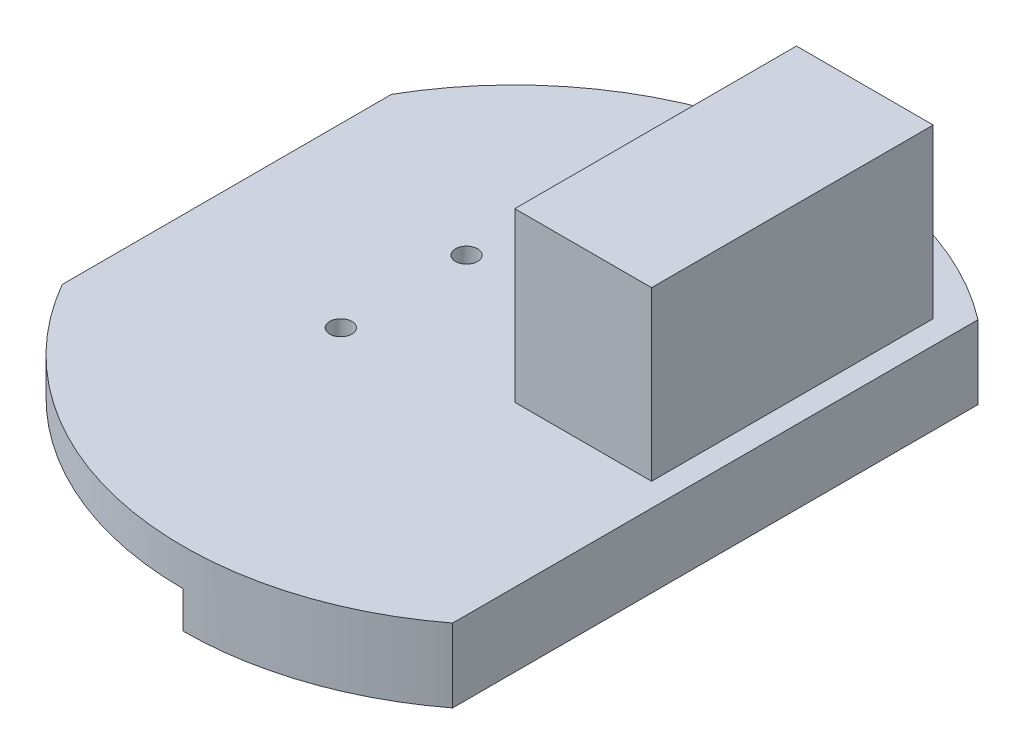
from build123d import *

# Parameters (mm, degrees)
SKETCH_1_R          = 1.5
EXTRUDE_1_DEPTH     = 5
SKETCH_3_W          = 18.6
SKETCH_3_H          = 38.3
SKETCH_3_W_2        = 12.6
SKETCH_3_H_2        = 32.3
EXTRUDE_3_DEPTH     = 19.8
SKETCH_4_W          = 18.6
SKETCH_4_H          = 38.3
EXTRUDE_4_DEPTH     = 3
SKETCH_7_W          = 12.6
SKETCH_7_H          = 32.3
CUT_EXTRUDE_1_DEPTH = 5
SKETCH_8_W          = 35.927581395
SKETCH_8_H          = 53.234071865
CUT_EXTRUDE_2_DEPTH = 14.8
SKETCH_9_W          = 12.6
SKETCH_9_H          = 4.7
EXTRUDE_5_DEPTH     = 15.2
SKETCH_10_R         = 1.1
CUT_EXTRUDE_3_DEPTH = 10
EXTRUDE_6_DEPTH     = 5
SKETCH_13_R         = 1
CUT_EXTRUDE_4_DEPTH = 5


with BuildPart() as part:
    # 草图1 → 凸台-拉伸1 (new body)
    with BuildSketch(Plane(origin=(0, 0, 0), x_dir=(1, 0, 0), z_dir=(0, 1, 0))):
        with BuildLine():
            Line((-39.038561358, -22.382822144), (-39.038561358, 22.382822144))
            ThreePointArc((-39.038561358, 22.382822144), (-8.857541047, 44.119655105), (27.374530931, 35.716033603))
            Line((27.374530931, 35.716033603), (27.374530931, -35.716033603))
            ThreePointArc((27.374530931, -35.716033603), (-8.857541047, -44.119655105), (-39.038561358, -22.382822144))
        make_face()
        with Locations((-15, 8.55)):
            Circle(SKETCH_1_R, mode=Mode.SUBTRACT)
        with Locations((-15, -8.55)):
            Circle(SKETCH_1_R, mode=Mode.SUBTRACT)
    extrude(amount=EXTRUDE_1_DEPTH)

    # 草图3 → 凸台-拉伸3 (add, symmetric)
    with BuildSketch(Plane(origin=(0, 5, 0), x_dir=(1, 0, 0), z_dir=(0, 1, 0))):
        with Locations((14.904530931, 13.65)):
            Rectangle(SKETCH_3_W, SKETCH_3_H)
        with Locations((14.904530931, 13.65)):
            Rectangle(SKETCH_3_W_2, SKETCH_3_H_2, mode=Mode.SUBTRACT)
    extrude(amount=EXTRUDE_3_DEPTH, both=True)

    # 草图4 → 凸台-拉伸4 (add)
    with BuildSketch(Plane(origin=(0, 24.8, 0), x_dir=(1, 0, 0), z_dir=(0, 1, 0))):
        with Locations((14.904530931, 13.65)):
            Rectangle(SKETCH_4_W, SKETCH_4_H)
    extrude(amount=EXTRUDE_4_DEPTH)

    # 草图7 → 切除-拉伸1 (cut)
    with BuildSketch(Plane(origin=(0, 0, 0), x_dir=(-1, 0, 0), z_dir=(0, -1, 0))):
        with Locations((-14.904530931, 13.65)):
            Rectangle(SKETCH_7_W, SKETCH_7_H)
    extrude(amount=-CUT_EXTRUDE_1_DEPTH, mode=Mode.SUBTRACT)

    # 草图8 → 切除-拉伸2 (cut)
    with BuildSketch(Plane(origin=(0, -14.8, 0), x_dir=(-1, 0, 0), z_dir=(0, -1, 0))):
        with Locations((-13.744141361, 17.136677553)):
            Rectangle(SKETCH_8_W, SKETCH_8_H)
    extrude(amount=-CUT_EXTRUDE_2_DEPTH, mode=Mode.SUBTRACT)

    # 草图9 → 凸台-拉伸5 (add)
    with BuildSketch(Plane.XZ.offset(-24.8)):
        with Locations((14.904530931, -27.45)):
            Rectangle(SKETCH_9_W, SKETCH_9_H)
    extrude_5 = extrude(amount=EXTRUDE_5_DEPTH)

    # 草图10 → 切除-拉伸3 (cut)
    with BuildSketch(Plane(origin=(0, 9.6, 0), x_dir=(-1, 0, 0), z_dir=(0, -1, 0))):
        with Locations((-14.904530931, 27.9)):
            Circle(SKETCH_10_R)
    cut_extrude_3 = extrude(amount=-CUT_EXTRUDE_3_DEPTH, mode=Mode.SUBTRACT)

    # 镜向1: 凸台-拉伸5, 切除-拉伸3 across plane
    add(extrude_5.mirror(Plane.XY.offset(-13.65)))
    add(cut_extrude_3.mirror(Plane.XY.offset(-13.65)), mode=Mode.SUBTRACT)

    # 草图11 → 凸台-拉伸6 (add)
    with BuildSketch(Plane(origin=(0, 0, 0), x_dir=(-1, 0, 0), z_dir=(0, -1, 0))):
        with BuildLine():
            Line((0, 42), (0, 45))
            ThreePointArc((0, 45), (-13.278516311, 42.996290591), (-25.374530931, 37.163600203))
            Line((-25.374530931, 37.163600203), (-25.374530931, 33.46839076))
            ThreePointArc((-25.374530931, 33.46839076), (-13.385208031, 39.810001331), (0, 42))
        make_face()
        with BuildLine():
            Line((0, -45), (0, -42))
            ThreePointArc((0, -42), (-13.385208031, -39.810001331), (-25.374530931, -33.46839076))
            Line((-25.374530931, -33.46839076), (-25.374530931, -37.163600203))
            ThreePointArc((-25.374530931, -37.163600203), (-13.278516311, -42.996290591), (0, -45))
        make_face()
        with BuildLine():
            Line((-25.374530931, 33.46839076), (-25.374530931, 37.163600203))
            ThreePointArc((-25.374530931, 37.163600203), (-26.384460277, 36.453535575), (-27.374530931, 35.716033603))
            Line((-27.374530931, 35.716033603), (-27.374530931, 31.853336659))
            ThreePointArc((-27.374530931, 31.853336659), (-26.386890339, 32.676168965), (-25.374530931, 33.46839076))
        make_face()
        with BuildLine():
            Line((-25.374530931, -37.163600203), (-25.374530931, -33.46839076))
            ThreePointArc((-25.374530931, -33.46839076), (-26.386890339, -32.676168965), (-27.374530931, -31.853336659))
            Line((-27.374530931, -31.853336659), (-27.374530931, -35.716033603))
            ThreePointArc((-27.374530931, -35.716033603), (-26.384460277, -36.453535575), (-25.374530931, -37.163600203))
        make_face()
        with BuildLine():
            Line((-25.374530931, -33.46839076), (-25.374530931, 33.46839076))
            ThreePointArc((-25.374530931, 33.46839076), (-26.386890339, 32.676168965), (-27.374530931, 31.853336659))
            Line((-27.374530931, 31.853336659), (-27.374530931, -31.853336659))
            ThreePointArc((-27.374530931, -31.853336659), (-26.386890339, -32.676168965), (-25.374530931, -33.46839076))
        make_face()
        with BuildLine():
            Line((-25.374530931, 33.46839076), (-25.374530931, 37.163600203))
            ThreePointArc((-25.374530931, 37.163600203), (-26.384460277, 36.453535575), (-27.374530931, 35.716033603))
            Line((-27.374530931, 35.716033603), (-27.374530931, 31.853336659))
            ThreePointArc((-27.374530931, 31.853336659), (-26.386890339, 32.676168965), (-25.374530931, 33.46839076))
        make_face()
        with BuildLine():
            Line((-25.374530931, -37.163600203), (-25.374530931, -33.46839076))
            ThreePointArc((-25.374530931, -33.46839076), (-26.386890339, -32.676168965), (-27.374530931, -31.853336659))
            Line((-27.374530931, -31.853336659), (-27.374530931, -35.716033603))
            ThreePointArc((-27.374530931, -35.716033603), (-26.384460277, -36.453535575), (-25.374530931, -37.163600203))
        make_face()
        with BuildLine():
            Line((0, 42), (0, 45))
            ThreePointArc((0, 45), (-13.278516311, 42.996290591), (-25.374530931, 37.163600203))
            Line((-25.374530931, 37.163600203), (-25.374530931, 33.46839076))
            ThreePointArc((-25.374530931, 33.46839076), (-13.385208031, 39.810001331), (0, 42))
        make_face()
        with BuildLine():
            Line((0, -45), (0, -42))
            ThreePointArc((0, -42), (-13.385208031, -39.810001331), (-25.374530931, -33.46839076))
            Line((-25.374530931, -33.46839076), (-25.374530931, -37.163600203))
            ThreePointArc((-25.374530931, -37.163600203), (-13.278516311, -42.996290591), (0, -45))
        make_face()
    extrude(amount=EXTRUDE_6_DEPTH)

    # 草图13 → 切除-拉伸4 (cut)
    with BuildSketch(Plane(origin=(0, -5, 0), x_dir=(-1, 0, 0), z_dir=(0, -1, 0))):
        with Locations((-5.074530931, 43.202999153)):
            Circle(SKETCH_13_R)
        with Locations((-26.074530931, 34.819087247)):
            Circle(SKETCH_13_R)
        with Locations((-26.074530931, -34.819087247)):
            Circle(SKETCH_13_R)
        with Locations((-5.074530931, -43.202999153)):
            Circle(SKETCH_13_R)
    extrude(amount=-CUT_EXTRUDE_4_DEPTH, mode=Mode.SUBTRACT)


solid = part.part
